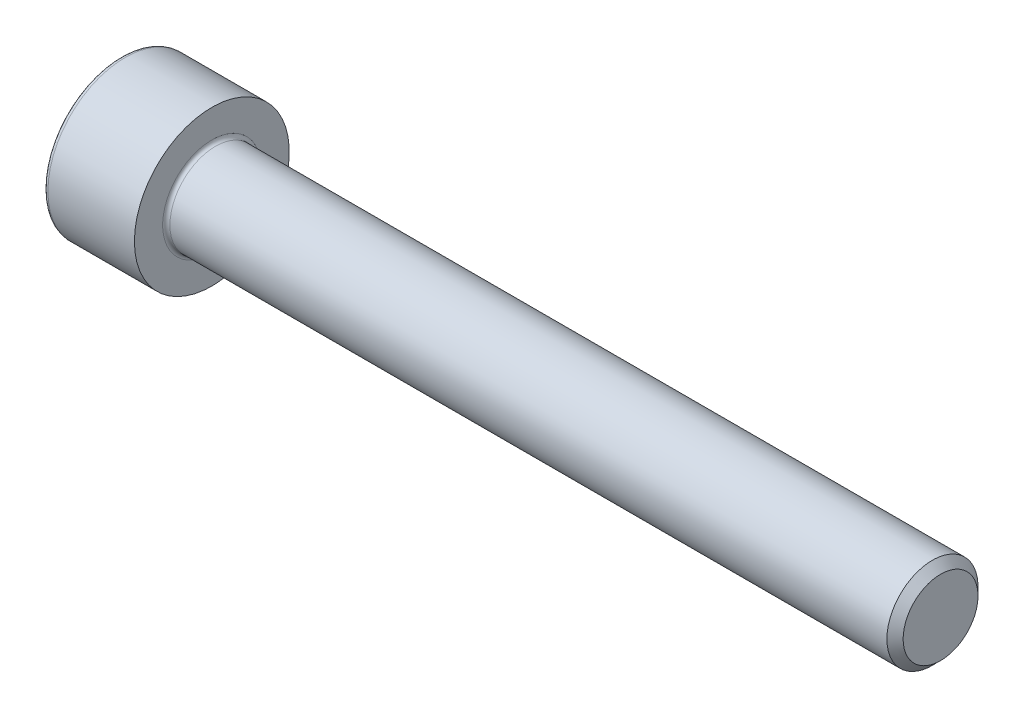
from build123d import *

# Parameters (mm, degrees)
FILLET1_R    = 0.2
FILLET2_R    = 0.25
HEX_2_DEPTH  = 2.5
SCALE1_SCALE = 0.630434783


with BuildPart() as part:
    # BodySke → Base-Revolve (revolve)
    with BuildSketch(Plane.XY):
        Polygon((0, 0), (0, 4.25), (5, 4.25), (5, 2.5), (44.555, 2.5), (45, 2.055), (45, 0), align=None)
    revolve(axis=Axis((-31.75, 0, 0), (1, 0, 0)))

    # Fillet1
    fillet1_edges = [part.edges().sort_by_distance(p)[0] for p in [
        (5, -2.5, 0),
    ]]
    fillet(fillet1_edges, radius=FILLET1_R)

    # Fillet2
    fillet2_edges = [part.edges().sort_by_distance(p)[0] for p in [
        (0, -4.25, 0),
    ]]
    fillet(fillet2_edges, radius=FILLET2_R)

    # Sketch2 → Hex-PreBroach (revolve, cut)
    with BuildSketch(Plane.XY):
        Polygon((0, 2.042), (2.5, 2.042), (3.67894925, 0), (0, 0), align=None)
    revolve(axis=Axis((0, 0, 0), (1, 0, 0)), mode=Mode.SUBTRACT)

    # Sketch3 → Hex 2 (cut)
    with BuildSketch(Plane(origin=(0, 0, 0), x_dir=(0, 0.5, 0.866025404), z_dir=(-1, 0, 0))):
        Polygon((1.17894925, 2.042), (-1.17894925, 2.042), (-2.357898499, 0), (-1.17894925, -2.042), (1.17894925, -2.042), (2.357898499, 0), align=None)
    extrude(amount=-HEX_2_DEPTH, mode=Mode.SUBTRACT)


with BuildPart() as part_1:
    # Scale1: scaled about (0, 0, 0)
    add(part.part.scale(SCALE1_SCALE))


solid = part_1.part
